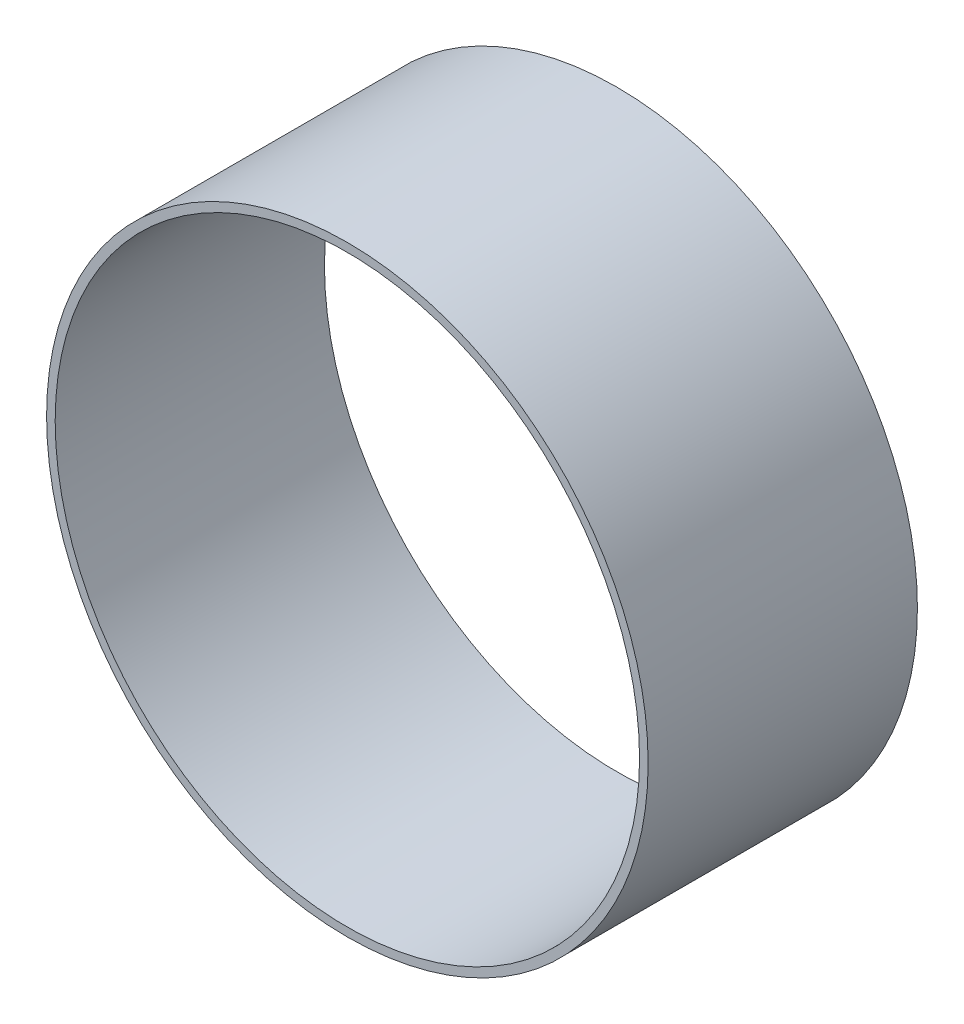
from build123d import *

# Parameters (mm, degrees)
SKETCH1_R           = 166.6875
SKETCH1_R_2         = 161.925
BOSS_EXTRUDE1_DEPTH = 74.6125


with BuildPart() as part:
    # Sketch1 → Boss-Extrude1 (new body, symmetric)
    with BuildSketch(Plane.XY):
        Circle(SKETCH1_R)
        Circle(SKETCH1_R_2, mode=Mode.SUBTRACT)
    extrude(amount=BOSS_EXTRUDE1_DEPTH, both=True)


solid = part.part
